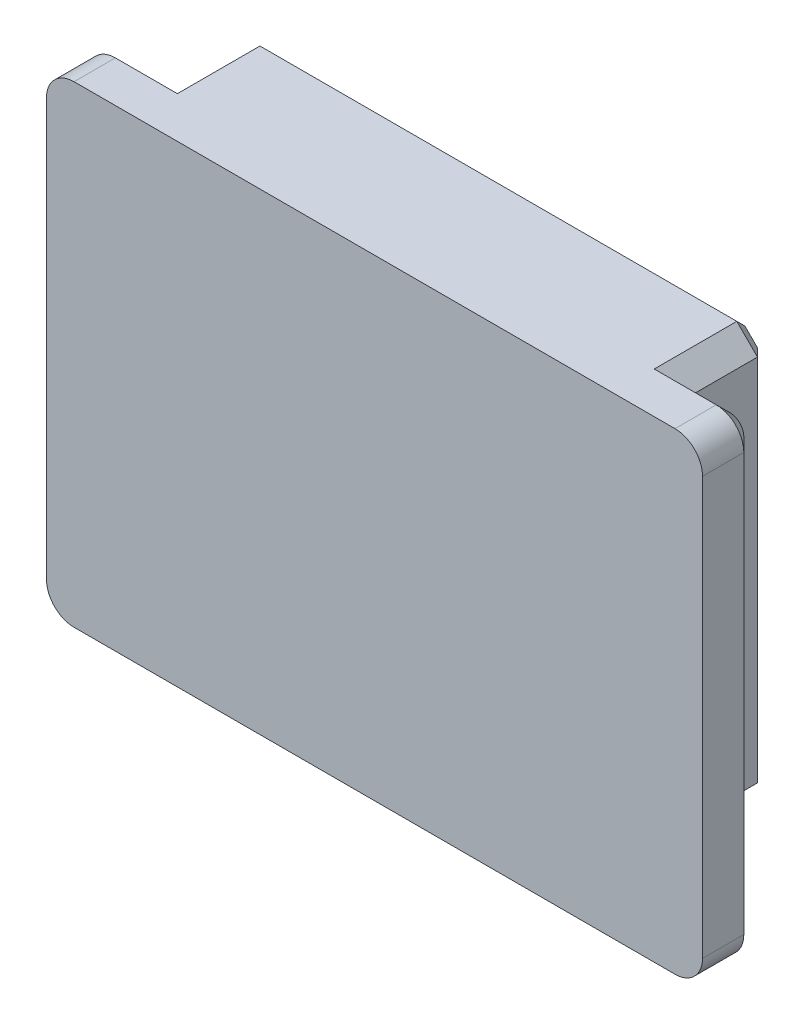
from build123d import *

# Parameters (mm, degrees)
SKETCH1_W           = 47.666666667
SKETCH1_H           = 34.333333333
BOSS_EXTRUDE1_DEPTH = 4
SKETCH1_3_W         = 37.651513934
SKETCH1_3_H         = 29.796380505
BOSS_EXTRUDE2_DEPTH = 6
FILLET1_R           = 2
CHAMFER1_SIZE       = 1.5
CHAMFER2_SIZE       = 1
CHAMFER3_SIZE       = 1


with BuildPart() as part:
    # Sketch1 → Boss-Extrude1 (new body)
    with BuildSketch(Plane.XY):
        with Locations((23.833333334, 17.166666666)):
            Rectangle(SKETCH1_W, SKETCH1_H)
    extrude(amount=BOSS_EXTRUDE1_DEPTH)

    # Sketch1_3 → Boss-Extrude2 (add)
    with BuildSketch(Plane.XY):
        with Locations((23.833333333, 19.43514308)):
            Rectangle(SKETCH1_3_W, SKETCH1_3_H)
    extrude(amount=-BOSS_EXTRUDE2_DEPTH)

    # Fillet1
    fillet1_edges = [part.edges().sort_by_distance(p)[0] for p in [
        (0, 34.333333333, 2),
        (47.666666667, 34.333333333, 2),
        (0, 0, 2),
        (47.666666667, 0, 2),
    ]]
    fillet(fillet1_edges, radius=FILLET1_R)

    # Chamfer1
    chamfer1_edges = [part.edges().sort_by_distance(p)[0] for p in [
        (5.007576366, 34.333333333, -3),
        (42.6590903, 34.333333333, -3),
        (42.6590903, 4.536952828, -3),
        (5.007576366, 4.536952828, -3),
    ]]
    chamfer(chamfer1_edges, length=CHAMFER1_SIZE)

    # Chamfer2
    chamfer2_edges = [part.edges().sort_by_distance(p)[0] for p in [
        (41.9090903, 33.583333333, -6),
        (23.833333333, 34.333333333, -6),
        (5.757576366, 33.583333333, -6),
        (5.007576366, 19.435143081, -6),
        (5.757576366, 5.286952828, -6),
        (42.6590903, 19.435143081, -6),
        (41.9090903, 5.286952828, -6),
        (23.833333333, 4.536952828, -6),
    ]]
    chamfer(chamfer2_edges, length=CHAMFER2_SIZE)

    # Chamfer3
    chamfer3_edges = [part.edges().sort_by_distance(p)[0] for p in [
        (4.253788183, 34.333333333, 0),
        (0.585786438, 33.747546896, 0),
        (0, 17.166666667, 0),
        (0.585786438, 0.585786438, 0),
        (23.833333333, 0, 0),
        (47.080880229, 0.585786438, 0),
        (47.666666667, 17.166666667, 0),
        (47.080880229, 33.747546896, 0),
        (43.412878483, 34.333333333, 0),
    ]]
    chamfer(chamfer3_edges, length=CHAMFER3_SIZE)


solid = part.part
